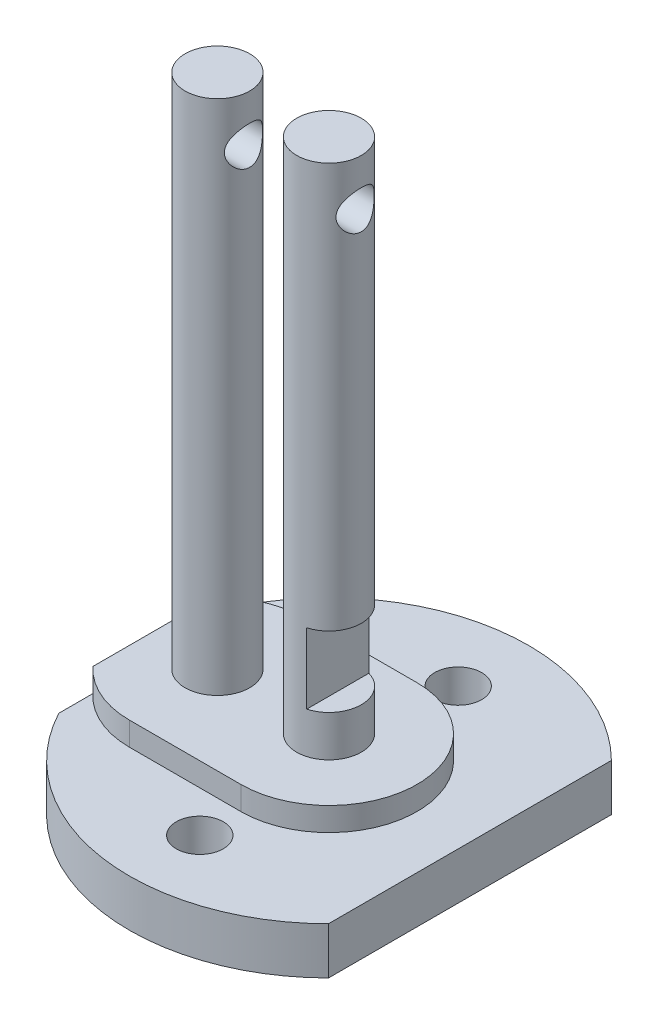
from build123d import *

# Parameters (mm, degrees)
BOSS_EXTRUDE1_DEPTH     = 4
SKETCH2_R               = 2.75
BOSS_EXTRUDE2_DEPTH     = 50
SKETCH3_W               = 2
SKETCH3_H               = 6
CUT_EXTRUDE1_DEPTH      = 18
CUT_EXTRUDE1_DEPTH_BACK = 18
BOSS_EXTRUDE3_DEPTH     = 6
SKETCH7_R               = 2
CUT_EXTRUDE3_DEPTH      = 10
SKETCH8_R               = 2.75
BOSS_EXTRUDE4_DEPTH     = 50
SKETCH6_R               = 1.625
CUT_EXTRUDE2_DEPTH      = 13
CUT_EXTRUDE2_DEPTH_BACK = 16


with BuildPart() as part:
    # Sketch1 → Boss-Extrude1 (new body)
    with BuildSketch(Plane(origin=(0, 0, 0), x_dir=(1, 0, 0), z_dir=(0, 1, 0))):
        with BuildLine():
            Line((-15, 8), (-15, -8))
            ThreePointArc((-15, -8), (-2.516668767, -16.812685042), (12, -12.041594579))
            Line((12, -12.041594579), (12, 12.041594579))
            ThreePointArc((12, 12.041594579), (-2.516668767, 16.812685042), (-15, 8))
        make_face()
    extrude(amount=BOSS_EXTRUDE1_DEPTH)

    # Sketch2 → Boss-Extrude2 (add)
    with BuildSketch(Plane(origin=(0, 0, 0), x_dir=(1, 0, 0), z_dir=(0, 1, 0))):
        Circle(SKETCH2_R)
    extrude(amount=BOSS_EXTRUDE2_DEPTH)

    # Sketch3 → Cut-Extrude1 (cut, two sides)
    with BuildSketch(Plane.XY) as cut_extrude1_sk:
        with Locations((1.75, 12.5)):
            Rectangle(SKETCH3_W, SKETCH3_H)
    extrude(amount=CUT_EXTRUDE1_DEPTH, mode=Mode.SUBTRACT)
    extrude(cut_extrude1_sk.sketch, amount=-CUT_EXTRUDE1_DEPTH_BACK, mode=Mode.SUBTRACT)

    # Sketch4 → Boss-Extrude3 (add)
    with BuildSketch(Plane(origin=(0, 0, 0), x_dir=(1, 0, 0), z_dir=(0, 1, 0))):
        with BuildLine():
            Line((0, -7.5), (-9.5, -7.5))
            ThreePointArc((-9.5, -7.5), (-12.500612741, -6.873596088), (-15, -5.099019514))
            Line((-15, -5.099019514), (-15, 5.099019514))
            ThreePointArc((-15, 5.099019514), (-12.500612741, 6.873596088), (-9.5, 7.5))
            Line((-9.5, 7.5), (0, 7.5))
            ThreePointArc((0, 7.5), (7.5, 0), (0, -7.5))
        make_face()
    extrude(amount=BOSS_EXTRUDE3_DEPTH)

    # Sketch7 → Cut-Extrude3 (cut)
    with BuildSketch(Plane(origin=(0, 0, 0), x_dir=(1, 0, 0), z_dir=(0, 1, 0))):
        with Locations((0, 11)):
            Circle(SKETCH7_R)
        with Locations((0, -11)):
            Circle(SKETCH7_R)
    extrude(amount=CUT_EXTRUDE3_DEPTH, mode=Mode.SUBTRACT)

    # Sketch8 → Boss-Extrude4 (add)
    with BuildSketch(Plane(origin=(0, 0, 0), x_dir=(1, 0, 0), z_dir=(0, 1, 0))):
        with Locations((-9.5, 0)):
            Circle(SKETCH8_R)
    extrude(amount=BOSS_EXTRUDE4_DEPTH)

    # Sketch6 → Cut-Extrude2 (cut, two sides)
    with BuildSketch(Plane(origin=(0, 0, 0), x_dir=(0, 0, -1), z_dir=(1, 0, 0))) as cut_extrude2_sk:
        with Locations((0, 46)):
            Circle(SKETCH6_R)
    extrude(amount=CUT_EXTRUDE2_DEPTH, mode=Mode.SUBTRACT)
    extrude(cut_extrude2_sk.sketch, amount=-CUT_EXTRUDE2_DEPTH_BACK, mode=Mode.SUBTRACT)


solid = part.part
